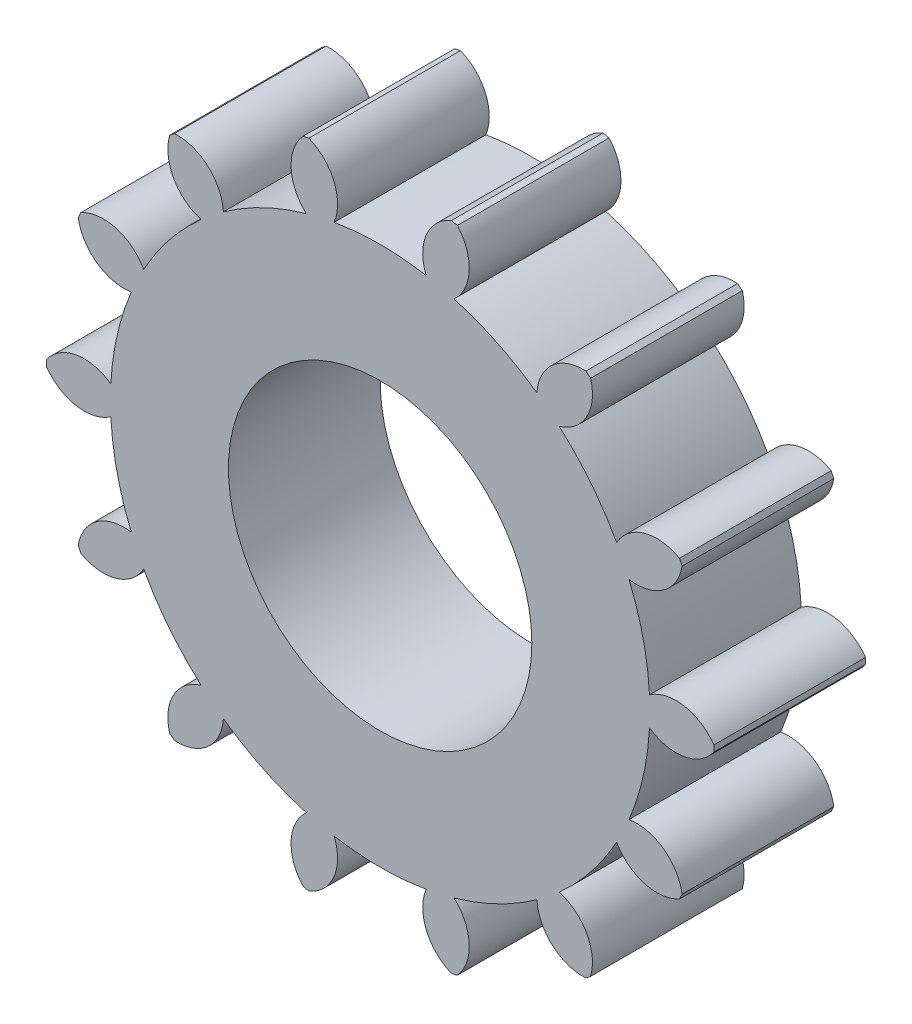
from build123d import *

# Parameters (mm, degrees)
SKETCH1_R           = 13.2
SKETCH1_R_2         = 6
BOSS_EXTRUDE1_DEPTH = 6
CUT_EXTRUDE1_DEPTH  = 7
CIRPATTERN2_COUNT   = 14


with BuildPart() as part:
    # Sketch1 → Boss-Extrude1 (new body)
    with BuildSketch(Plane.XY):
        Circle(SKETCH1_R)
        Circle(SKETCH1_R_2, mode=Mode.SUBTRACT)
    extrude(amount=BOSS_EXTRUDE1_DEPTH)

    # Sketch2 → Cut-Extrude1 (cut, through all)
    with BuildSketch(Plane.XY.offset(6)):
        with BuildLine():
            ThreePointArc((-2.819851171, 12.895287487), (0, 13.2), (2.819851171, 12.895287487))
            ThreePointArc((2.819851171, 12.895287487), (1.826256171, 11.910750525), (1.819851171, 10.512))
            ThreePointArc((1.819851171, 10.512), (0, 10.668364555), (-1.819851171, 10.512))
            ThreePointArc((-1.819851171, 10.512), (-1.826256171, 11.910750525), (-2.819851171, 12.895287487))
        make_face()
    cut_extrude1 = extrude(amount=-CUT_EXTRUDE1_DEPTH, mode=Mode.SUBTRACT)

    # CirPattern2: Cut-Extrude1 ×14 about axis
    cirpattern2_axis = Axis((0, 0, 0), (0, 0, 1))
    for i in range(1, CIRPATTERN2_COUNT):
        add(cut_extrude1.rotate(cirpattern2_axis, i * 360 / CIRPATTERN2_COUNT), mode=Mode.SUBTRACT)


solid = part.part
